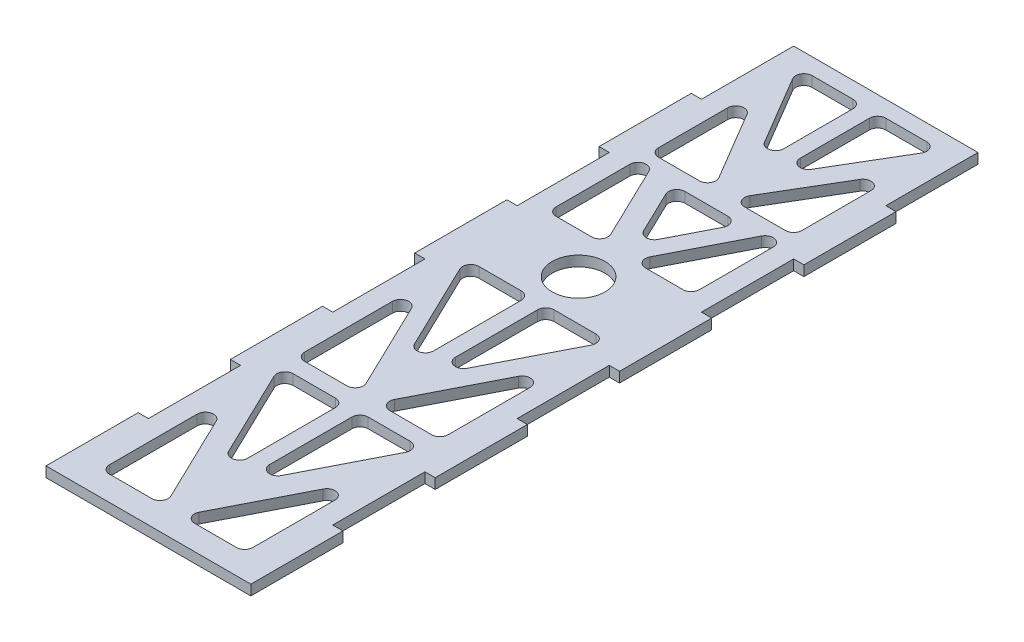
from build123d import *

# Parameters (mm, degrees)
SKETCH1_R           = 8.1915
BOSS_EXTRUDE1_DEPTH = 3.175


with BuildPart() as part:
    # Sketch1 → Boss-Extrude1 (new body)
    with BuildSketch(Plane(origin=(0, -9.743731804, 0), x_dir=(1, 0, 0), z_dir=(0, 1, 0))):
        Polygon((-31.75, 143.175862399), (-28.575, 143.175862399), (-28.575, 171.750862399), (28.575, 171.750862399), (28.575, 143.175862399), (31.75, 143.175862399), (31.75, 114.600862399), (28.575, 114.600862399), (28.575, 86.025862399), (31.75, 86.025862399), (31.75, 57.450862399), (28.575, 57.450862399), (28.575, 28.875862399), (31.75, 28.875862399), (31.75, 0.300862399), (28.575, 0.300862399), (28.575, -28.274137601), (31.75, -28.274137601), (31.75, -56.849137601), (-31.75, -56.849137601), (-31.75, -28.274137601), (-28.575, -28.274137601), (-28.575, 0.300862399), (-31.75, 0.300862399), (-31.75, 28.875862399), (-28.575, 28.875862399), (-28.575, 57.450862399), (-31.75, 57.450862399), (-31.75, 86.025862399), (-28.575, 86.025862399), (-28.575, 114.600862399), (-31.75, 114.600862399), align=None)
        with Locations((0, 76.500862399)):
            Circle(SKETCH1_R, mode=Mode.SUBTRACT)
        with BuildLine():
            Line((-17.769774531, 166.670862399), (-5.08, 166.670862399))
            ThreePointArc((-5.08, 166.670862399), (-3.283948776, 165.926913623), (-2.54, 164.130862399))
            Line((-2.54, 164.130862399), (-2.54, 142.693779868))
            ThreePointArc((-2.54, 142.693779868), (-4.409257974, 140.243942091), (-7.265752074, 141.399914392))
            Line((-7.265752074, 141.399914392), (-19.955526605, 162.836996923))
            ThreePointArc((-19.955526605, 162.836996923), (-19.976357671, 165.388873069), (-17.769774531, 166.670862399))
        make_face(mode=Mode.SUBTRACT)
        with BuildLine():
            Line((2.54, 164.130862399), (2.54, 142.693779868))
            ThreePointArc((2.54, 142.693779868), (4.409257974, 140.243942091), (7.265752074, 141.399914392))
            Line((7.265752074, 141.399914392), (19.955526605, 162.836996923))
            ThreePointArc((19.955526605, 162.836996923), (19.976357671, 165.388873069), (17.769774531, 166.670862399))
            Line((17.769774531, 166.670862399), (5.08, 166.670862399))
            ThreePointArc((5.08, 166.670862399), (3.283948776, 165.926913623), (2.54, 164.130862399))
        make_face(mode=Mode.SUBTRACT)
        with BuildLine():
            Line((-22.225, 144.92794493), (-22.225, 123.490862399))
            ThreePointArc((-22.225, 123.490862399), (-21.481051224, 121.694811175), (-19.685, 120.950862399))
            Line((-19.685, 120.950862399), (-6.995225469, 120.950862399))
            ThreePointArc((-6.995225469, 120.950862399), (-4.788642329, 122.232851729), (-4.809473395, 124.784727875))
            Line((-4.809473395, 124.784727875), (-17.499247926, 146.221810406))
            ThreePointArc((-17.499247926, 146.221810406), (-20.355742026, 147.377782707), (-22.225, 144.92794493))
        make_face(mode=Mode.SUBTRACT)
        with BuildLine():
            Line((4.809473395, 124.784727875), (17.499247926, 146.221810406))
            ThreePointArc((17.499247926, 146.221810406), (20.355742026, 147.377782707), (22.225, 144.92794493))
            Line((22.225, 144.92794493), (22.225, 123.490862399))
            ThreePointArc((22.225, 123.490862399), (21.481051224, 121.694811175), (19.685, 120.950862399))
            Line((19.685, 120.950862399), (6.995225469, 120.950862399))
            ThreePointArc((6.995225469, 120.950862399), (4.788642329, 122.232851729), (4.809473395, 124.784727875))
        make_face(mode=Mode.SUBTRACT)
        with BuildLine():
            Line((5.749780192, 92.89598746), (17.422858074, 115.75598746))
            ThreePointArc((17.422858074, 115.75598746), (20.279036829, 117.070421114), (22.225, 114.600862399))
            Line((22.225, 114.600862399), (22.225, 91.740862399))
            ThreePointArc((22.225, 91.740862399), (21.481051224, 89.944811175), (19.685, 89.200862399))
            Line((19.685, 89.200862399), (8.011922118, 89.200862399))
            ThreePointArc((8.011922118, 89.200862399), (5.845632934, 90.414668155), (5.749780192, 92.89598746))
        make_face(mode=Mode.SUBTRACT)
        with BuildLine():
            Line((-6.372736394, 92.844195759), (-17.397150465, 115.704195759))
            ThreePointArc((-17.397150465, 115.704195759), (-20.250889645, 117.077022513), (-22.225, 114.600862399))
            Line((-22.225, 114.600862399), (-22.225, 91.740862399))
            ThreePointArc((-22.225, 91.740862399), (-21.481051224, 89.944811175), (-19.685, 89.200862399))
            Line((-19.685, 89.200862399), (-8.66058593, 89.200862399))
            ThreePointArc((-8.66058593, 89.200862399), (-6.509531917, 90.390097196), (-6.372736394, 92.844195759))
        make_face(mode=Mode.SUBTRACT)
        with BuildLine():
            Line((5.08, 63.800862399), (18.076004066, 63.800862399))
            ThreePointArc((18.076004066, 63.800862399), (20.24229325, 62.587056643), (20.338145992, 60.105737338))
            Line((20.338145992, 60.105737338), (7.342141926, 34.654981681))
            ThreePointArc((7.342141926, 34.654981681), (4.485963171, 33.340548027), (2.54, 35.810106741))
            Line((2.54, 35.810106741), (2.54, 61.260862399))
            ThreePointArc((2.54, 61.260862399), (3.283948776, 63.056913623), (5.08, 63.800862399))
        make_face(mode=Mode.SUBTRACT)
        with BuildLine():
            Line((-5.08, 63.800862399), (-18.180124412, 63.800862399))
            ThreePointArc((-18.180124412, 63.800862399), (-20.331178425, 62.611627602), (-20.467973948, 60.157529039))
            Line((-20.467973948, 60.157529039), (-7.367849535, 32.993378441))
            ThreePointArc((-7.367849535, 32.993378441), (-4.514110355, 31.620551687), (-2.54, 34.096711801))
            Line((-2.54, 34.096711801), (-2.54, 61.260862399))
            ThreePointArc((-2.54, 61.260862399), (-3.283948776, 63.056913623), (-5.08, 63.800862399))
        make_face(mode=Mode.SUBTRACT)
        with BuildLine():
            Line((17.422858074, 40.433585982), (4.426854008, 14.982830325))
            ThreePointArc((4.426854008, 14.982830325), (4.52270675, 12.50151102), (6.688995934, 11.287705264))
            Line((6.688995934, 11.287705264), (19.685, 11.287705264))
            ThreePointArc((19.685, 11.287705264), (21.481051224, 12.03165404), (22.225, 13.827705264))
            Line((22.225, 13.827705264), (22.225, 39.278460922))
            ThreePointArc((22.225, 39.278460922), (20.279036829, 41.748019636), (17.422858074, 40.433585982))
        make_face(mode=Mode.SUBTRACT)
        with BuildLine():
            Line((-22.225, 40.991855862), (-22.225, 13.827705264))
            ThreePointArc((-22.225, 13.827705264), (-21.481051224, 12.03165404), (-19.685, 11.287705264))
            Line((-19.685, 11.287705264), (-6.584875588, 11.287705264))
            ThreePointArc((-6.584875588, 11.287705264), (-4.433821575, 12.476940061), (-4.297026052, 14.931038624))
            Line((-4.297026052, 14.931038624), (-17.397150465, 42.095189222))
            ThreePointArc((-17.397150465, 42.095189222), (-20.250889645, 43.468015976), (-22.225, 40.991855862))
        make_face(mode=Mode.SUBTRACT)
        with BuildLine():
            Line((-18.180124412, 6.207705264), (-5.08, 6.207705264))
            ThreePointArc((-5.08, 6.207705264), (-3.283948776, 5.463756488), (-2.54, 3.667705264))
            Line((-2.54, 3.667705264), (-2.54, -23.496445334))
            ThreePointArc((-2.54, -23.496445334), (-4.514110355, -25.972605448), (-7.367849535, -24.599778694))
            Line((-7.367849535, -24.599778694), (-20.467973948, 2.564371904))
            ThreePointArc((-20.467973948, 2.564371904), (-20.331178425, 5.018470467), (-18.180124412, 6.207705264))
        make_face(mode=Mode.SUBTRACT)
        with BuildLine():
            Line((2.54, 3.667705264), (2.54, -21.783050394))
            ThreePointArc((2.54, -21.783050394), (4.485963171, -24.252609108), (7.342141926, -22.938175454))
            Line((7.342141926, -22.938175454), (20.338145992, 2.512580203))
            ThreePointArc((20.338145992, 2.512580203), (20.24229325, 4.993899508), (18.076004066, 6.207705264))
            Line((18.076004066, 6.207705264), (5.08, 6.207705264))
            ThreePointArc((5.08, 6.207705264), (3.283948776, 5.463756488), (2.54, 3.667705264))
        make_face(mode=Mode.SUBTRACT)
        with BuildLine():
            Line((4.426854008, -45.53401254), (17.422858074, -20.083256883))
            ThreePointArc((17.422858074, -20.083256883), (20.279036829, -18.768823229), (22.225, -21.238381943))
            Line((22.225, -21.238381943), (22.225, -46.689137601))
            ThreePointArc((22.225, -46.689137601), (21.481051224, -48.485188825), (19.685, -49.229137601))
            Line((19.685, -49.229137601), (6.688995934, -49.229137601))
            ThreePointArc((6.688995934, -49.229137601), (4.52270675, -48.015331845), (4.426854008, -45.53401254))
        make_face(mode=Mode.SUBTRACT)
        with BuildLine():
            Line((-17.397150465, -18.421653643), (-4.297026052, -45.585804241))
            ThreePointArc((-4.297026052, -45.585804241), (-4.433821575, -48.039902804), (-6.584875588, -49.229137601))
            Line((-6.584875588, -49.229137601), (-19.685, -49.229137601))
            ThreePointArc((-19.685, -49.229137601), (-21.481051224, -48.485188825), (-22.225, -46.689137601))
            Line((-22.225, -46.689137601), (-22.225, -19.524987003))
            ThreePointArc((-22.225, -19.524987003), (-20.250889645, -17.048826889), (-17.397150465, -18.421653643))
        make_face(mode=Mode.SUBTRACT)
        with BuildLine():
            Line((6.89223147, 115.870862399), (-6.382799442, 115.870862399))
            ThreePointArc((-6.382799442, 115.870862399), (-8.533853455, 114.681627602), (-8.670648977, 112.227529039))
            Line((-8.670648977, 112.227529039), (-2.222824791, 98.857452412))
            ThreePointArc((-2.222824791, 98.857452412), (0.036114273, 97.420950308), (2.32716667, 98.805660711))
            Line((2.32716667, 98.805660711), (9.154373397, 112.175737338))
            ThreePointArc((9.154373397, 112.175737338), (9.058520654, 114.657056643), (6.89223147, 115.870862399))
        make_face(mode=Mode.SUBTRACT)
    extrude(amount=BOSS_EXTRUDE1_DEPTH)


solid = part.part
